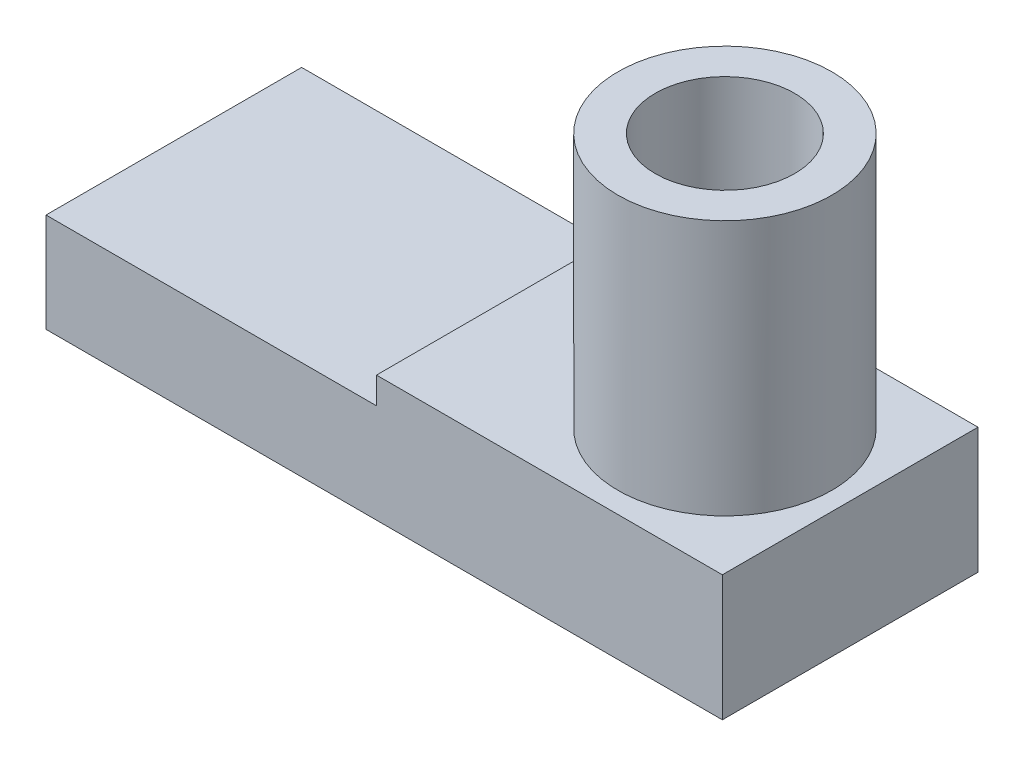
from build123d import *

# Parameters (mm, degrees)
P_IDAT_VYSUNUT_M1_DEPTH = 30
SKICA2_R                = 25.104353528
SKICA2_R_2              = 16.352413197
P_IDAT_VYSUNUT_M2_DEPTH = 60


with BuildPart() as part:
    # Skica1 → Přidat vysunutím1 (new body, symmetric)
    with BuildSketch(Plane.XY):
        Polygon((0, 0), (0, 23.242356394), (77.561836829, 23.242356394), (77.561836829, 29.488625529), (158.739934736, 29.488625529), (158.739934736, 0), align=None)
    extrude(amount=P_IDAT_VYSUNUT_M1_DEPTH, both=True)

    # Skica2 → Přidat vysunutím2 (add)
    with BuildSketch(Plane(origin=(0, 29.488625529, 0), x_dir=(1, 0, 0), z_dir=(0, 1, 0))):
        with Locations(Location((129.340120448, 0, 0), (0, 0, 90))):  # turned: the seam where the file's is
            Circle(SKICA2_R)
        with Locations(Location((129.340120448, 0, 0), (0, 0, 270))):  # turned: the seam where the file's is
            Circle(SKICA2_R_2, mode=Mode.SUBTRACT)
    extrude(amount=P_IDAT_VYSUNUT_M2_DEPTH)


solid = part.part
